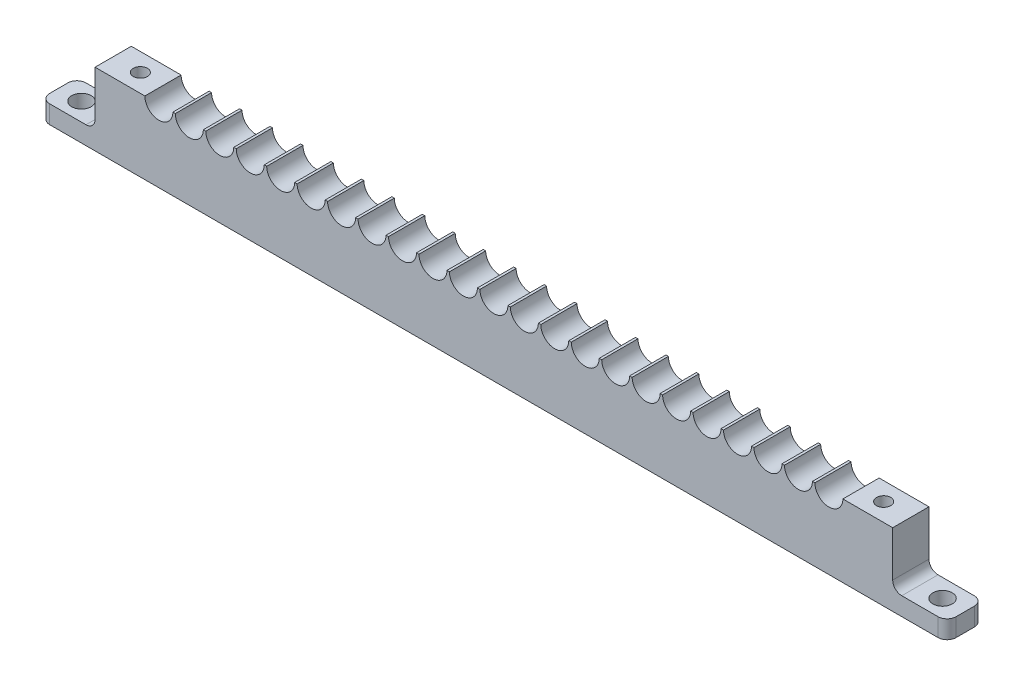
from build123d import *

# Parameters (mm, degrees)
SKETCH1_W                   = 139.7
SKETCH1_H                   = 12.7
BOSS_EXTRUDE1_DEPTH         = 6.35
SKETCH2_R                   = 2.4511
CUT_EXTRUDE1_DEPTH          = 7.35
TAP_DRILL_FOR_M3X0_5_TAP1_D = 2.5
SKETCH5_W                   = 9.525
SKETCH5_H                   = 6.35
BOSS_EXTRUDE2_DEPTH         = 3.175
FILLET1_R                   = 1.5875
M3_CLEARANCE_HOLE1_D        = 3.4
FILLET2_R                   = 1.5875
FILLET2_OF_MIRROR5_R        = 1.5875
FILLET3_R                   = 1.5875


with BuildPart() as part:
    # Sketch1 → Boss-Extrude1 (new body)
    with BuildSketch(Plane.XY):
        Rectangle(SKETCH1_W, SKETCH1_H)
    extrude(amount=BOSS_EXTRUDE1_DEPTH)

    # Sketch2 → Cut-Extrude1 (cut, through all)
    with BuildSketch(Plane.XY.offset(6.35)):
        with Locations((0, 6.35)):
            Circle(SKETCH2_R)
        with Locations((5.334, 6.35)):
            Circle(SKETCH2_R)
        with Locations((10.668, 6.35)):
            Circle(SKETCH2_R)
        with Locations((16.002, 6.35)):
            Circle(SKETCH2_R)
        with Locations((21.336, 6.35)):
            Circle(SKETCH2_R)
        with Locations((26.67, 6.35)):
            Circle(SKETCH2_R)
        with Locations((32.004, 6.35)):
            Circle(SKETCH2_R)
        with Locations((37.338, 6.35)):
            Circle(SKETCH2_R)
        with Locations((42.672, 6.35)):
            Circle(SKETCH2_R)
        with Locations((48.006, 6.35)):
            Circle(SKETCH2_R)
        with Locations((53.34, 6.35)):
            Circle(SKETCH2_R)
        with Locations((58.674, 6.35)):
            Circle(SKETCH2_R)
        with Locations((-5.334, 6.35)):
            Circle(SKETCH2_R)
        with Locations((-10.668, 6.35)):
            Circle(SKETCH2_R)
        with Locations((-16.002, 6.35)):
            Circle(SKETCH2_R)
        with Locations((-21.336, 6.35)):
            Circle(SKETCH2_R)
        with Locations((-26.67, 6.35)):
            Circle(SKETCH2_R)
        with Locations((-32.004, 6.35)):
            Circle(SKETCH2_R)
        with Locations((-37.338, 6.35)):
            Circle(SKETCH2_R)
        with Locations((-42.672, 6.35)):
            Circle(SKETCH2_R)
        with Locations((-48.006, 6.35)):
            Circle(SKETCH2_R)
        with Locations((-53.34, 6.35)):
            Circle(SKETCH2_R)
        with Locations((-58.674, 6.35)):
            Circle(SKETCH2_R)
    extrude(amount=-CUT_EXTRUDE1_DEPTH, mode=Mode.SUBTRACT)

    # Tap Drill for M3x0.5 Tap1 (through all)
    with Locations(Plane(origin=(0, 6.35, 0), x_dir=(1, 0, 0), z_dir=(0, 1, 0))):
        with Locations((-65.0875, -3.175), (65.0875, -3.175)):
            Hole(TAP_DRILL_FOR_M3X0_5_TAP1_D / 2)

    # Sketch5 → Boss-Extrude2 (add)
    with BuildSketch(Plane.XZ.offset(6.35)):
        with Locations((-74.6125, 3.175)):
            Rectangle(SKETCH5_W, SKETCH5_H)
    boss_extrude2 = extrude(amount=-BOSS_EXTRUDE2_DEPTH)

    # Fillet1
    fillet1_edges = [part.edges().sort_by_distance(p)[0] for p in [
        (-69.85, -3.175, 3.175),
    ]]
    fillet(fillet1_edges, radius=FILLET1_R)

    # M3 Clearance Hole1 (through all)
    with Locations(Plane(origin=(0, -3.175, 0), x_dir=(1, 0, 0), z_dir=(0, 1, 0))):
        with Locations((-75.40625, -3.175)):
            m3_clearance_hole1 = Hole(M3_CLEARANCE_HOLE1_D / 2)

    # Fillet2
    fillet2_edges = [part.edges().sort_by_distance(p)[0] for p in [
        (-79.375, -4.7625, 0),
        (-79.375, -4.7625, 6.35),
    ]]
    fillet(fillet2_edges, radius=FILLET2_R)

    # Mirror5: Boss-Extrude2, M3 Clearance Hole1 across plane
    add(boss_extrude2.mirror(Plane(origin=(0, 0, 0), x_dir=(0, 0, 1), z_dir=(1, 0, 0))))
    add(m3_clearance_hole1.mirror(Plane(origin=(0, 0, 0), x_dir=(0, 0, 1), z_dir=(1, 0, 0))), mode=Mode.SUBTRACT)

    # Fillet2 of Mirror5
    fillet2_of_mirror5_edges = [part.edges().sort_by_distance(p)[0] for p in [
        (79.375, -4.7625, 0),
        (79.375, -4.7625, 6.35),
    ]]
    fillet(fillet2_of_mirror5_edges, radius=FILLET2_OF_MIRROR5_R)

    # Fillet3
    fillet3_edges = [part.edges().sort_by_distance(p)[0] for p in [
        (69.85, -3.175, 3.175),
    ]]
    fillet(fillet3_edges, radius=FILLET3_R)


solid = part.part
